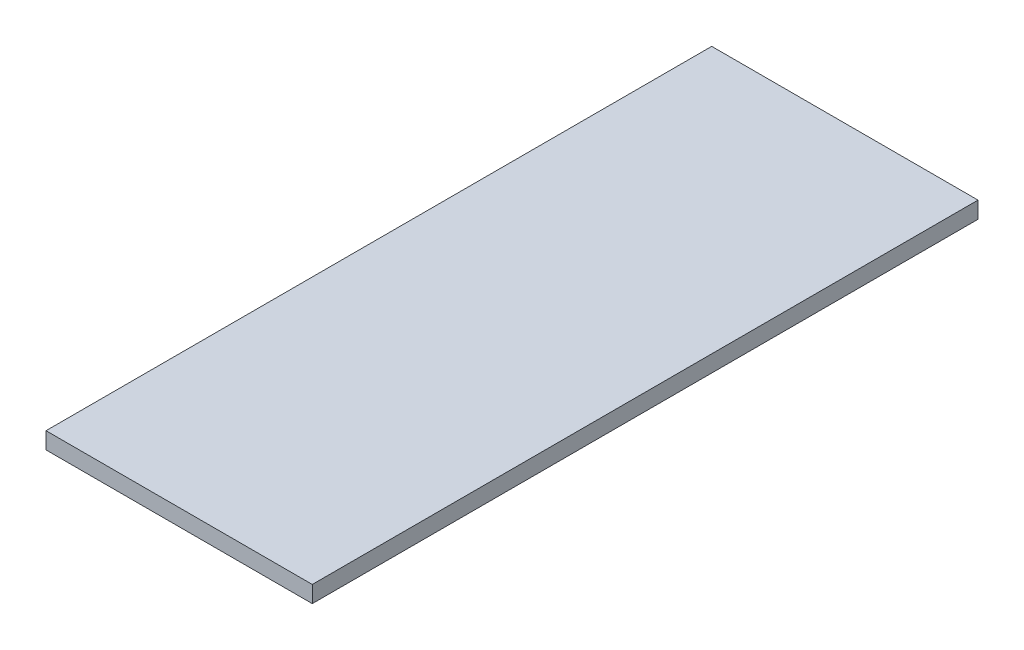
from build123d import *

# Parameters (mm, degrees)
SKETCH2_W           = 101.6
SKETCH2_H           = 254
BOSS_EXTRUDE2_DEPTH = 6.35


with BuildPart() as part:
    # Sketch2 → Boss-Extrude2 (new body)
    with BuildSketch(Plane(origin=(0, 0, 0), x_dir=(1, 0, 0), z_dir=(0, 1, 0))):
        with Locations((-50.8, 127)):
            Rectangle(SKETCH2_W, SKETCH2_H)
    extrude(amount=BOSS_EXTRUDE2_DEPTH)


solid = part.part
